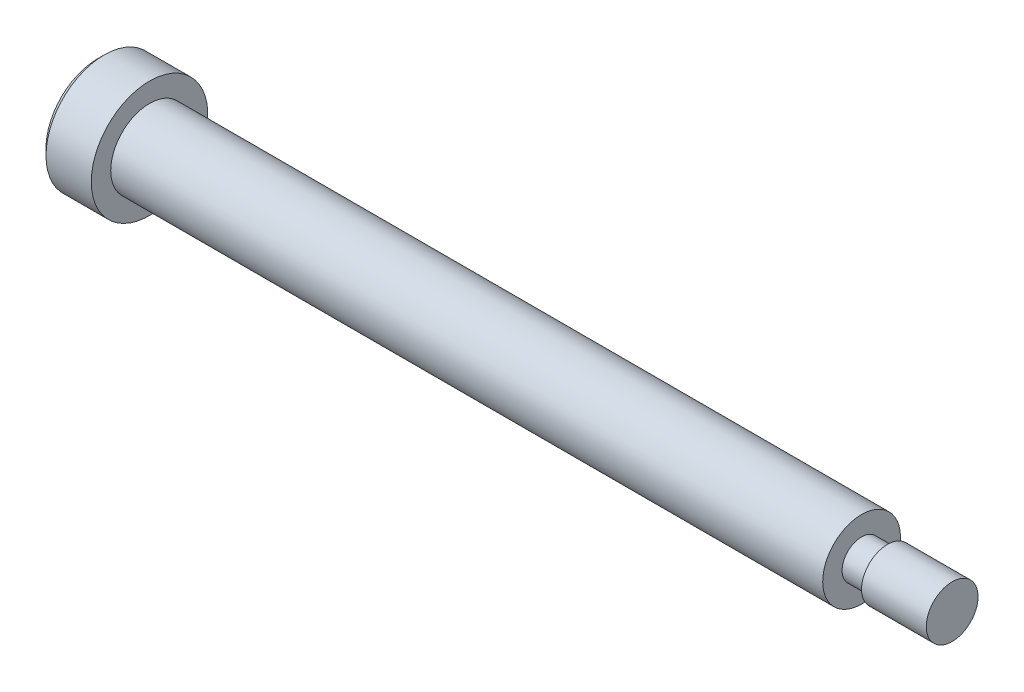
from build123d import *

# Parameters (mm, degrees)
CHAMFER2_SIZE      = 0.5
CUT_EXTRUDE1_DEPTH = 2


with BuildPart() as part:
    # Sketch1 → Revolve1 (revolve)
    with BuildSketch(Plane.XY):
        Polygon((0, 3), (55, 3), (55, 1.5), (57, 1.5), (57, 2), (62, 2), (62, 0), (-4, 0), (-4, 4.5), (0, 4.5), align=None)
    revolve(axis=Axis((-15.448246648, 0, 0), (1, 0, 0)))

    # Chamfer2
    chamfer2_edges = [part.edges().sort_by_distance(p)[0] for p in [
        (-4, -4.5, 0),
    ]]
    chamfer(chamfer2_edges, length=CHAMFER2_SIZE)

    # Sketch2 → Cut-Extrude1 (cut)
    with BuildSketch(Plane.ZY.offset(4)):
        Polygon((0, 1.732050808), (-1.5, 0.866025404), (-1.5, -0.866025404), (0, -1.732050808), (1.5, -0.866025404), (1.5, 0.866025404), align=None)
    extrude(amount=-CUT_EXTRUDE1_DEPTH, mode=Mode.SUBTRACT)


solid = part.part
